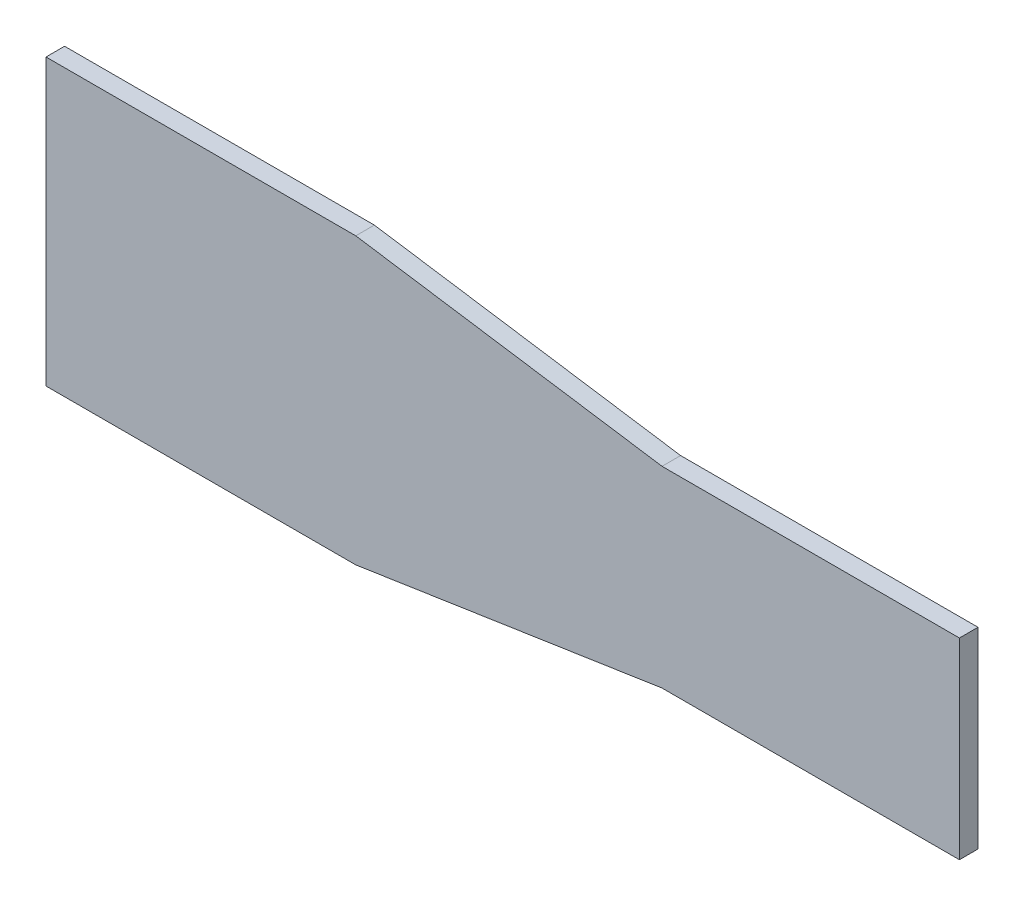
from build123d import *

# Parameters (mm, degrees)
BOSS_EXTRU_1_DEPTH = 3


with BuildPart() as part:
    # Esquisse1 → Boss.-Extru.1 (new body)
    with BuildSketch(Plane.XY):
        Polygon((0, 15.5), (-49.434299833, 23), (-99.434299833, 23), (-99.434299833, -23), (-49.434299833, -23), (0, -15.5), (48, -15.5), (48, 15.5), align=None)
    extrude(amount=BOSS_EXTRU_1_DEPTH)


solid = part.part
